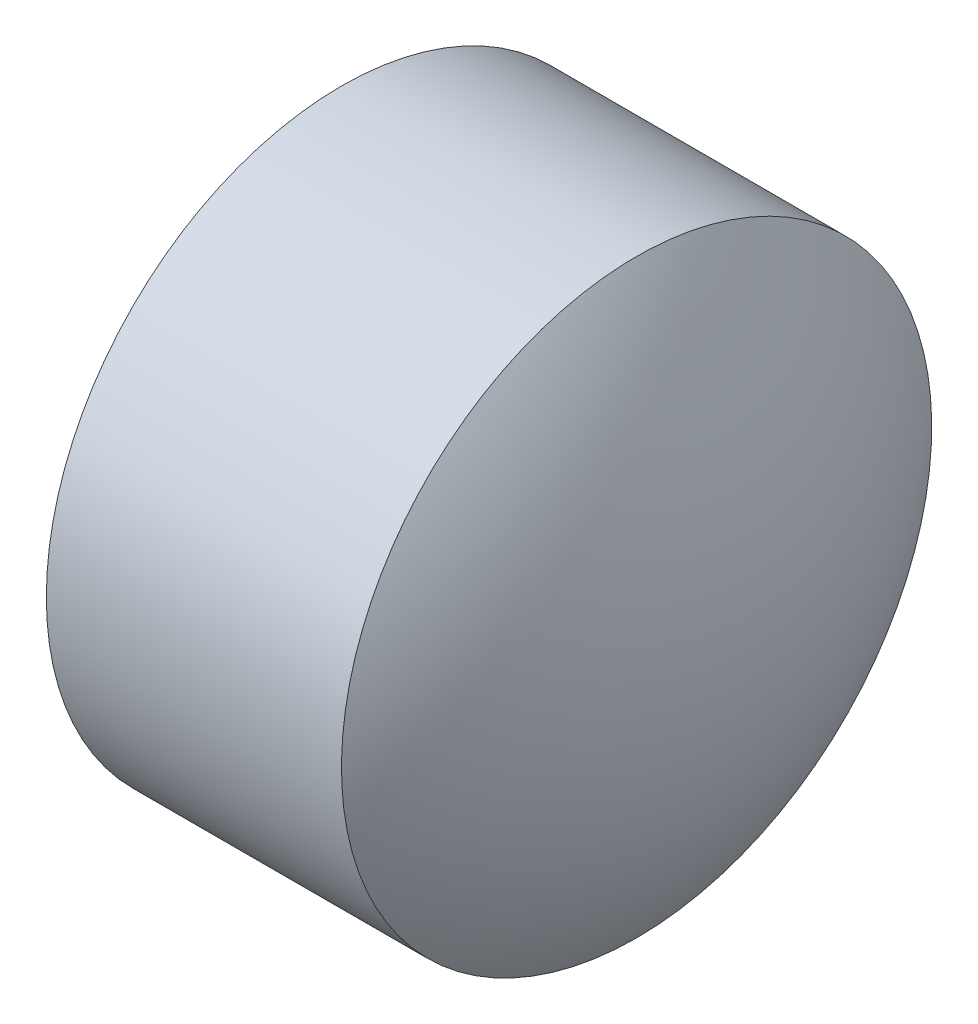
from build123d import *

# Parameters (mm, degrees)
SKETCH_2_ONE_SIDE_W = 1
SKETCH_2_ONE_SIDE_H = 1


with BuildPart() as part:
    # 草图2 one side → 旋转1 (revolve)
    with BuildSketch(Plane.XY, mode=Mode.PRIVATE) as revolve_1_sk:
        with Locations((6.807731793, 4.328040396)):
            Rectangle(SKETCH_2_ONE_SIDE_W, SKETCH_2_ONE_SIDE_H)
        with BuildLine():
            Line((5.992731793, 3.828040396), (6.307731793, 3.828040396))
            Line((6.307731793, 3.828040396), (6.307731793, 4.828040396))
            ThreePointArc((6.307731793, 4.828040396), (6.07334399, 4.352260054), (5.992731793, 3.828040396))
        make_face()
        with BuildLine():
            Line((7.307731793, 3.828040396), (7.622731793, 3.828040396))
            ThreePointArc((7.622731793, 3.828040396), (7.542119597, 4.352260054), (7.307731793, 4.828040396))
            Line((7.307731793, 4.828040396), (7.307731793, 3.828040396))
        make_face()
    revolve(revolve_1_sk.sketch.rotate(Axis((5.877930206, 3.828040396, 0), (1, 0, 0)), 180), axis=Axis((5.877930206, 3.828040396, 0), (1, 0, 0)))  # turned: the seam where the file's is


solid = part.part
